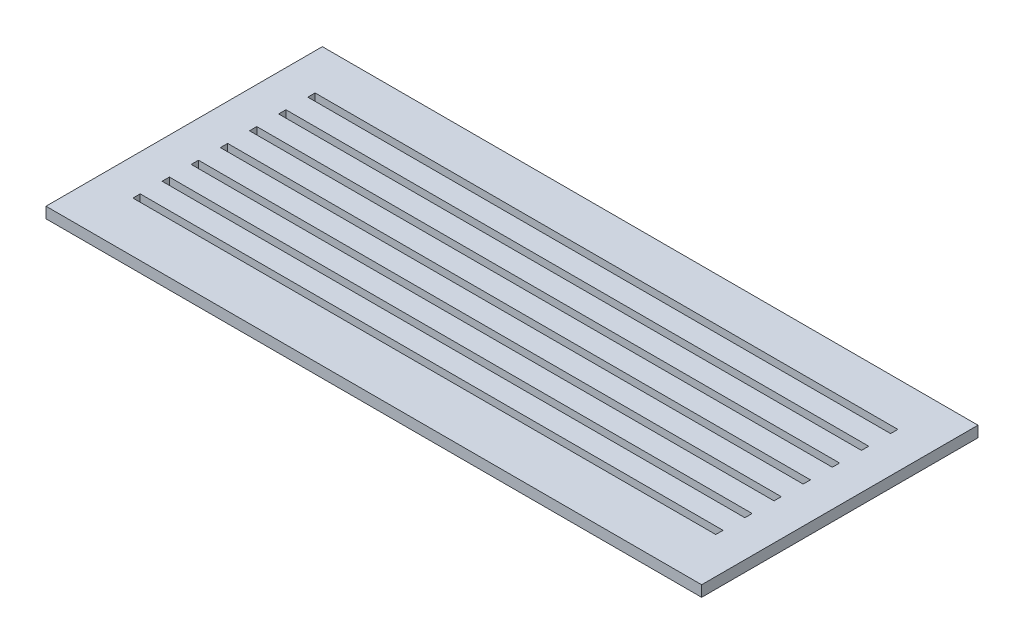
from build123d import *

# Parameters (mm, degrees)
SKETCH1_W           = 180
SKETCH1_H           = 75.87
SKETCH1_W_2         = 160
SKETCH1_H_2         = 2
BOSS_EXTRUDE1_DEPTH = 3


with BuildPart() as part:
    # Sketch1 → Boss-Extrude1 (new body)
    with BuildSketch(Plane(origin=(0, 0, 0), x_dir=(1, 0, 0), z_dir=(0, 1, 0))):
        with Locations((-5.566969943, 7.461475771)):
            Rectangle(SKETCH1_W, SKETCH1_H)
        with Locations((-5.566969943, 24.396475771)):
            Rectangle(SKETCH1_W_2, SKETCH1_H_2, mode=Mode.SUBTRACT)
        with Locations((-5.566969943, 32.396475771)):
            Rectangle(SKETCH1_W_2, SKETCH1_H_2, mode=Mode.SUBTRACT)
        with Locations((-5.566969943, 16.396475771)):
            Rectangle(SKETCH1_W_2, SKETCH1_H_2, mode=Mode.SUBTRACT)
        with Locations((-5.566969943, 8.396475771)):
            Rectangle(SKETCH1_W_2, SKETCH1_H_2, mode=Mode.SUBTRACT)
        with Locations((-5.566969943, 0.396475771)):
            Rectangle(SKETCH1_W_2, SKETCH1_H_2, mode=Mode.SUBTRACT)
        with Locations((-5.566969943, -7.603524229)):
            Rectangle(SKETCH1_W_2, SKETCH1_H_2, mode=Mode.SUBTRACT)
        with Locations((-5.566969943, -15.603524229)):
            Rectangle(SKETCH1_W_2, SKETCH1_H_2, mode=Mode.SUBTRACT)
    extrude(amount=BOSS_EXTRUDE1_DEPTH)


solid = part.part
